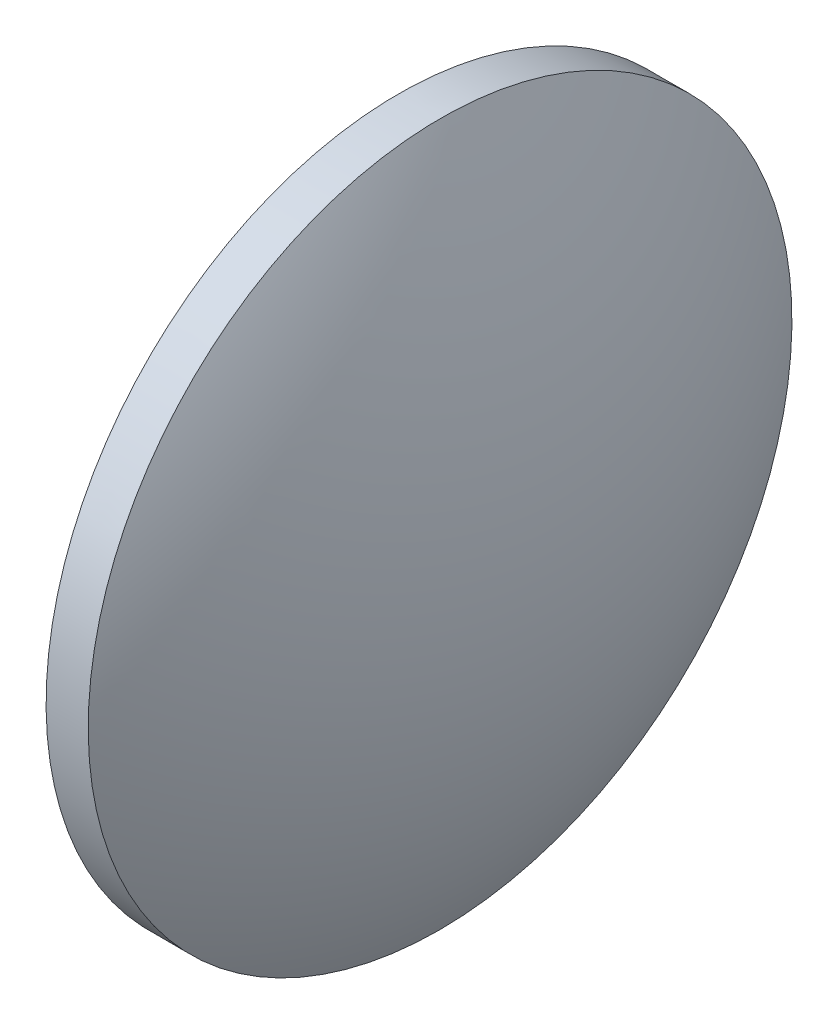
from build123d import *


with BuildPart() as part:
    # 草图1 → 旋转1 (revolve)
    with BuildSketch(Plane.XY, mode=Mode.PRIVATE) as revolve_1_sk:
        with BuildLine():
            Line((559.132768364, 117.904508853), (559.132768364, 142.904508853))
            Line((559.132768364, 142.904508853), (562.132768364, 142.904508853))
            ThreePointArc((562.132768364, 142.904508853), (566.946584392, 130.80494478), (568.582765103, 117.886152723))
            Line((568.582765103, 117.886152723), (559.132768364, 117.904508853))
        make_face()
    revolve(revolve_1_sk.sketch.rotate(Axis((554.484921311, 117.913537056, 0), (0.999998113, -0.001942445, 0)), 180), axis=Axis((554.484921311, 117.913537056, 0), (0.999998113, -0.001942445, 0)))  # turned: the seam where the file's is


solid = part.part
